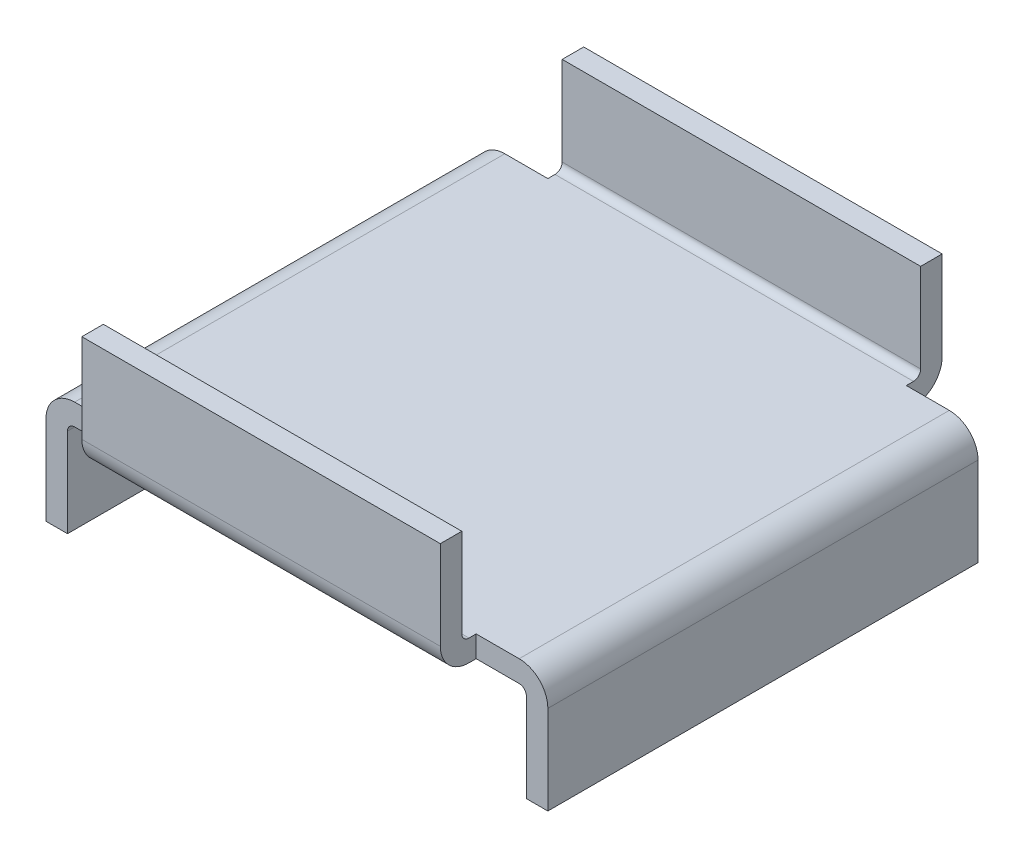
from build123d import *

# Parameters (mm, degrees)
SKETCH1_W           = 25
SKETCH1_H           = 35
BOSS_EXTRUDE1_DEPTH = 8.2
SKETCH2_W           = 32
SKETCH2_H           = 6.7
CUT_EXTRUDE1_DEPTH  = 26
SKETCH3_W           = 30
SKETCH3_H           = 1.5
BOSS_EXTRUDE2_DEPTH = 5
SKETCH4_W           = 1.5
SKETCH4_H           = 30
BOSS_EXTRUDE3_DEPTH = 6.7
SKETCH5_W           = 30
SKETCH5_H           = 1.5
BOSS_EXTRUDE4_DEPTH = 5
SKETCH6_W           = 1.5
SKETCH6_H           = 30
BOSS_EXTRUDE5_DEPTH = 6.7
FILLET1_R           = 0.5
FILLET2_R           = 2


with BuildPart() as part:
    # Sketch1 → Boss-Extrude1 (new body)
    with BuildSketch(Plane(origin=(0, 6.7, 0), x_dir=(1, 0, 0), z_dir=(0, 1, 0))):
        Rectangle(SKETCH1_W, SKETCH1_H)
    extrude(amount=-BOSS_EXTRUDE1_DEPTH)

    # Sketch2 → Cut-Extrude1 (cut, through all)
    with BuildSketch(Plane(origin=(12.5, 0, 0), x_dir=(0, 0, -1), z_dir=(1, 0, 0))):
        with Locations((0, 3.35)):
            Rectangle(SKETCH2_W, SKETCH2_H)
    extrude(amount=-CUT_EXTRUDE1_DEPTH, mode=Mode.SUBTRACT)

    # Sketch3 → Boss-Extrude2 (add)
    with BuildSketch(Plane.ZY.offset(12.5)):
        with Locations((0, -0.75)):
            Rectangle(SKETCH3_W, SKETCH3_H)
    extrude(amount=BOSS_EXTRUDE2_DEPTH)

    # Sketch4 → Boss-Extrude3 (add)
    with BuildSketch(Plane.XZ.offset(1.5)):
        with Locations((-16.75, 0)):
            Rectangle(SKETCH4_W, SKETCH4_H)
    extrude(amount=BOSS_EXTRUDE3_DEPTH)

    # Sketch5 → Boss-Extrude4 (add)
    with BuildSketch(Plane(origin=(12.5, 0, 0), x_dir=(0, 0, -1), z_dir=(1, 0, 0))):
        with Locations((0, -0.75)):
            Rectangle(SKETCH5_W, SKETCH5_H)
    extrude(amount=BOSS_EXTRUDE4_DEPTH)

    # Sketch6 → Boss-Extrude5 (add)
    with BuildSketch(Plane.XZ.offset(1.5)):
        with Locations((16.75, 0)):
            Rectangle(SKETCH6_W, SKETCH6_H)
    extrude(amount=BOSS_EXTRUDE5_DEPTH)

    # Fillet1
    fillet1_edges = [part.edges().sort_by_distance(p)[0] for p in [
        (0, 0, -16),
        (0, 0, 16),
        (-16, -1.5, 0),
        (16, -1.5, 0),
    ]]
    fillet(fillet1_edges, radius=FILLET1_R)

    # Fillet2
    fillet2_edges = [part.edges().sort_by_distance(p)[0] for p in [
        (0, -1.5, -17.5),
        (-17.5, 0, 0),
        (0, -1.5, 17.5),
        (17.5, 0, 0),
    ]]
    fillet(fillet2_edges, radius=FILLET2_R)


solid = part.part
